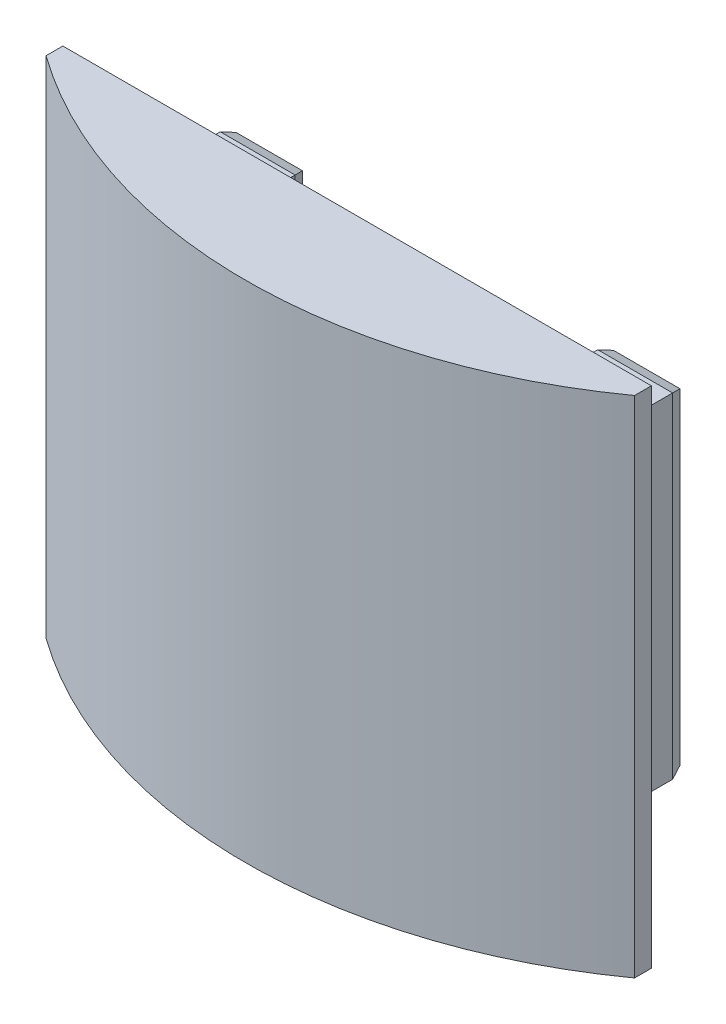
from build123d import *

# Parameters (mm, degrees)
SKETCH2_W             = 53.8
SKETCH2_H             = 39.8
BOSS_EXTRUDE1_DEPTH   = 12
SKETCH3_W             = 70
SKETCH3_H             = 60
BOSS_EXTRUDE2_DEPTH   = 31.5
SKETCH4_R             = 2.1
CUT_EXTRUDE1_DEPTH    = 50.9
SKETCH5_W             = 36
SKETCH5_H             = 39.8
CUT_EXTRUDE2_DEPTH    = 12
CHAMFER1_SIZE         = 0.5
CHAMFER1_SIZE2        = 1.37373871
CHAMFER1_PART_2_SIZE  = 0.5
CHAMFER1_PART_2_SIZE2 = 1.37373871
CUT_EXTRUDE13_DEPTH   = 61


with BuildPart() as part:
    # Sketch2 → Boss-Extrude1 (new body)
    with BuildSketch(Plane.XY):
        Rectangle(SKETCH2_W, SKETCH2_H)
    extrude(amount=BOSS_EXTRUDE1_DEPTH)

    # Sketch3 → Boss-Extrude2 (add)
    with BuildSketch(Plane.XY.offset(12)):
        Rectangle(SKETCH3_W, SKETCH3_H)
    extrude(amount=BOSS_EXTRUDE2_DEPTH)

    # Sketch4 → Cut-Extrude1 (cut, through all)
    with BuildSketch(Plane(origin=(0, 19.9, 0), x_dir=(1, 0, 0), z_dir=(0, 1, 0))):
        with Locations((22.5, -4.6)):
            Circle(SKETCH4_R)
        with Locations((-22.5, -4.6)):
            Circle(SKETCH4_R)
    extrude(amount=-CUT_EXTRUDE1_DEPTH, mode=Mode.SUBTRACT)

    # Sketch5 → Cut-Extrude2 (cut)
    with BuildSketch(Plane(origin=(0, 0, 0), x_dir=(-1, 0, 0), z_dir=(0, 0, -1))):
        Rectangle(SKETCH5_W, SKETCH5_H)
    extrude(amount=-CUT_EXTRUDE2_DEPTH, mode=Mode.SUBTRACT)

    # Chamfer1
    chamfer1_edges = [part.edges().sort_by_distance(p)[0] for p in [
        (-22.45, 19.9, 0),
        (-18, 0, 0),
        (-22.45, -19.9, 0),
        (-26.9, 0, 0),
    ]]
    chamfer1_side = [part.faces().sort_by_distance(p)[0] for p in [
        (-22.45, 0, 0),
    ]]
    chamfer(chamfer1_edges, length=CHAMFER1_SIZE, length2=CHAMFER1_SIZE2, reference=chamfer1_side[0])

    # Chamfer1 part 2
    chamfer1_part_2_edges = [part.edges().sort_by_distance(p)[0] for p in [
        (22.45, -19.9, 0),
        (18, 0, 0),
        (22.45, 19.9, 0),
        (26.9, 0, 0),
    ]]
    chamfer1_part_2_side = [part.faces().sort_by_distance(p)[0] for p in [
        (22.45, 0, 0),
    ]]
    chamfer(chamfer1_part_2_edges, length=CHAMFER1_PART_2_SIZE, length2=CHAMFER1_PART_2_SIZE2, reference=chamfer1_part_2_side[0])

    # Sketch27 → Cut-Extrude13 (cut, through all)
    with BuildSketch(Plane.XZ.offset(30)):
        with BuildLine():
            ThreePointArc((-35, 14), (0, 25.266028276), (35, 14))
            ThreePointArc((35, 14), (0, 140.049707845), (-35, 14))
        make_face()
    extrude(amount=-CUT_EXTRUDE13_DEPTH, mode=Mode.SUBTRACT)


solid = part.part
